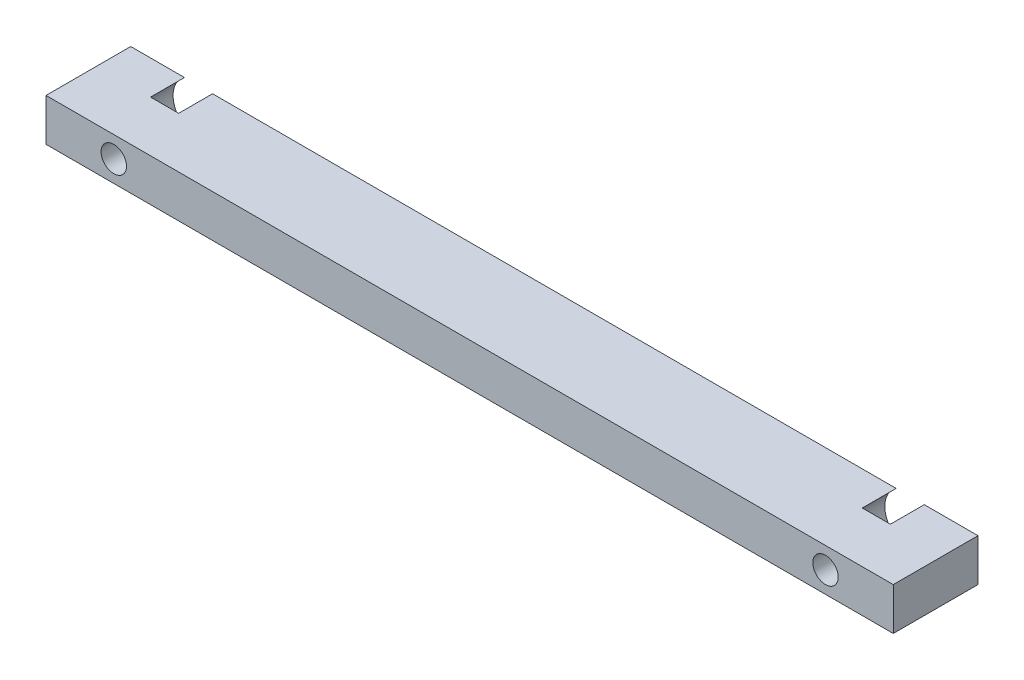
from build123d import *

# Parameters (mm, degrees)
SKETCH1_W           = 100
SKETCH1_H           = 5
BOSS_EXTRUDE1_DEPTH = 10
SKETCH2_R           = 3
CUT_EXTRUDE3_DEPTH  = 4
SKETCH3_R           = 1.5
CUT_EXTRUDE4_DEPTH  = 7


with BuildPart() as part:
    # Sketch1 → Boss-Extrude1 (new body)
    with BuildSketch(Plane.XY):
        Rectangle(SKETCH1_W, SKETCH1_H)
    extrude(amount=BOSS_EXTRUDE1_DEPTH)

    # Sketch2 → Cut-Extrude3 (cut)
    with BuildSketch(Plane(origin=(0, 0, 0), x_dir=(-1, 0, 0), z_dir=(0, 0, -1))):
        with Locations((-42, 0)):
            Circle(SKETCH2_R)
        with Locations((42, 0)):
            Circle(SKETCH2_R)
    extrude(amount=-CUT_EXTRUDE3_DEPTH, mode=Mode.SUBTRACT)

    # Sketch3 → Cut-Extrude4 (cut, through all)
    with BuildSketch(Plane(origin=(0, 0, 4), x_dir=(-1, 0, 0), z_dir=(0, 0, -1))):
        with Locations((-42, 0)):
            Circle(SKETCH3_R)
        with Locations((42, 0)):
            Circle(SKETCH3_R)
    extrude(amount=-CUT_EXTRUDE4_DEPTH, mode=Mode.SUBTRACT)


solid = part.part
